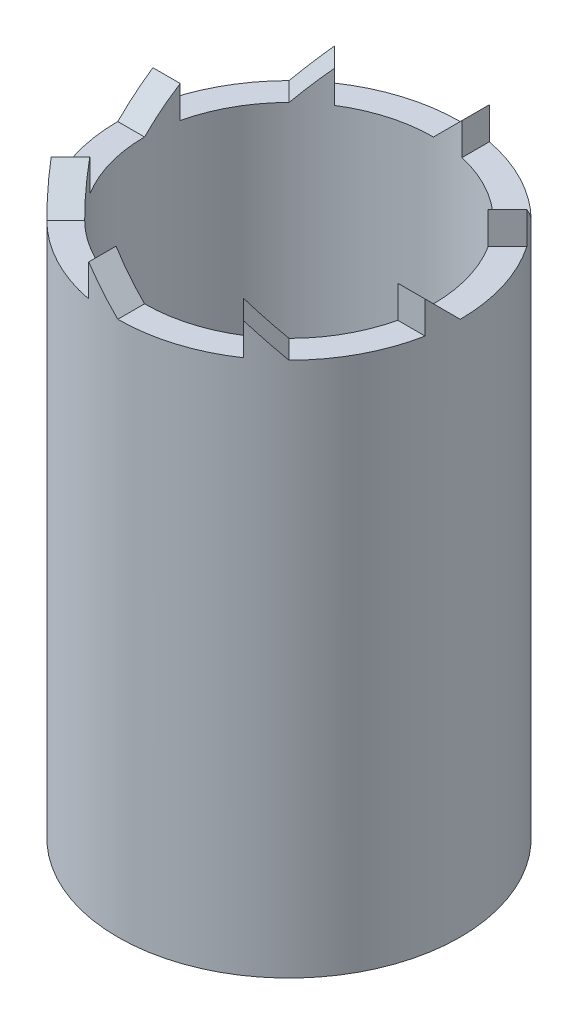
from build123d import *

# Parameters (mm, degrees)
SKETCH1_R           = 8.25
SKETCH1_R_2         = 6.75
BOSS_EXTRUDE1_DEPTH = 25
SKETCH2_W           = 1.5
SKETCH2_H           = 1.75
SKETCH2_W_2         = 1.75
SKETCH2_H_2         = 1.5
SKETCH2_H_3         = 1.499622071
BOSS_EXTRUDE2_DEPTH = 1.5
CUT_EXTRUDE1_DEPTH  = 2.5
CUT_EXTRUDE2_DEPTH  = 2.5
CUT_EXTRUDE3_DEPTH  = 2.5
CUT_EXTRUDE4_DEPTH  = 2.5
SKETCH9_R           = 6.625
CUT_EXTRUDE7_DEPTH  = 2.5
CUT_EXTRUDE10_DEPTH = 20.91726189
CUT_EXTRUDE11_DEPTH = 20.91726189
CUT_EXTRUDE12_DEPTH = 20.91726189
CUT_EXTRUDE13_DEPTH = 20.91726189
SKETCH15_R          = 10.332276799
SKETCH15_R_2        = 8
CUT_EXTRUDE14_DEPTH = 35
SKETCH16_R          = 6.75
CUT_EXTRUDE15_DEPTH = 40


with BuildPart() as part:
    # Sketch1 → Boss-Extrude1 (new body)
    with BuildSketch(Plane(origin=(0, 0, 0), x_dir=(1, 0, 0), z_dir=(0, 1, 0))):
        Circle(SKETCH1_R)
        Circle(SKETCH1_R_2, mode=Mode.SUBTRACT)
    extrude(amount=BOSS_EXTRUDE1_DEPTH)

    # Sketch2 → Boss-Extrude2 (add)
    with BuildSketch(Plane(origin=(0, 25, 0), x_dir=(1, 0, 0), z_dir=(0, 1, 0))):
        with Locations((0.75, 7.375)):
            Rectangle(SKETCH2_W, SKETCH2_H)
        with Locations((7.375, -0.75)):
            Rectangle(SKETCH2_W_2, SKETCH2_H_2)
        with Locations((-0.75, -7.375)):
            Rectangle(SKETCH2_W, SKETCH2_H)
        with Locations((-7.375, 0.749811036)):
            Rectangle(SKETCH2_W_2, SKETCH2_H_3)
        Polygon((-5.833630945, 5.833630945), (-4.772970773, 6.894291117), (-3.535533906, 5.656854249), (-4.596194078, 4.596194078), align=None)
        Polygon((5.833630945, 5.833630945), (6.894291117, 4.772970773), (5.656854249, 3.535533906), (4.596194078, 4.596194078), align=None)
        Polygon((5.833630945, -5.833630945), (4.772970773, -6.894291117), (3.535533906, -5.656854249), (4.596194078, -4.596194078), align=None)
        Polygon((-5.833630945, -5.833630945), (-6.894291117, -4.772970773), (-5.656854249, -3.535533906), (-4.596194078, -4.596194078), align=None)
    extrude(amount=BOSS_EXTRUDE2_DEPTH)

    # Sketch5 → Cut-Extrude1 (cut)
    with BuildSketch(Plane.XY.offset(8.25)):
        Polygon((-1.5, 26.5), (0, 25), (0, 26.5), align=None)
    extrude(amount=-CUT_EXTRUDE1_DEPTH, mode=Mode.SUBTRACT)

    # Sketch6 → Cut-Extrude2 (cut)
    with BuildSketch(Plane.ZY.offset(8.25)):
        Polygon((0, 26.5), (-1.499622071, 26.5), (0, 25), align=None)
    extrude(amount=-CUT_EXTRUDE2_DEPTH, mode=Mode.SUBTRACT)

    # Sketch7 → Cut-Extrude3 (cut)
    with BuildSketch(Plane(origin=(0, 0, -8.25), x_dir=(-1, 0, 0), z_dir=(0, 0, -1))):
        Polygon((-1.5, 26.5), (0, 26.5), (0, 25), align=None)
    extrude(amount=-CUT_EXTRUDE3_DEPTH, mode=Mode.SUBTRACT)

    # Sketch8 → Cut-Extrude4 (cut)
    with BuildSketch(Plane(origin=(8.25, 0, 0), x_dir=(0, 0, -1), z_dir=(1, 0, 0))):
        Polygon((0, 26.5), (-1.5, 26.5), (0, 25), align=None)
    extrude(amount=-CUT_EXTRUDE4_DEPTH, mode=Mode.SUBTRACT)

    # Sketch9 → Cut-Extrude7 (cut)
    with BuildSketch(Plane(origin=(0, 25, 0), x_dir=(1, 0, 0), z_dir=(0, 1, 0))):
        Circle(SKETCH9_R)
    extrude(amount=CUT_EXTRUDE7_DEPTH, mode=Mode.SUBTRACT)

    # Sketch11 → Cut-Extrude10 (cut, through all)
    with BuildSketch(Plane(origin=(-5.833630945, 0, 5.833630945), x_dir=(0.707106781, 0, 0.707106781), z_dir=(-0.707106781, 0, 0.707106781))):
        Polygon((0, 25), (-1.5, 26.5), (0, 26.5), align=None)
    extrude(amount=-CUT_EXTRUDE10_DEPTH, mode=Mode.SUBTRACT)

    # Sketch12 → Cut-Extrude11 (cut, through all)
    with BuildSketch(Plane(origin=(-5.833630945, 0, -5.833630945), x_dir=(-0.707106781, 0, 0.707106781), z_dir=(-0.707106781, 0, -0.707106781))):
        Polygon((0, 25), (-1.5, 26.5), (0, 26.5), align=None)
    extrude(amount=-CUT_EXTRUDE11_DEPTH, mode=Mode.SUBTRACT)

    # Sketch13 → Cut-Extrude12 (cut, through all)
    with BuildSketch(Plane(origin=(5.833630945, 0, -5.833630945), x_dir=(-0.707106781, 0, -0.707106781), z_dir=(0.707106781, 0, -0.707106781))):
        Polygon((0, 25), (-1.5, 26.5), (0, 26.5), align=None)
    extrude(amount=-CUT_EXTRUDE12_DEPTH, mode=Mode.SUBTRACT)

    # Sketch14 → Cut-Extrude13 (cut, through all)
    with BuildSketch(Plane(origin=(5.833630945, 0, 5.833630945), x_dir=(0.707106781, 0, -0.707106781), z_dir=(0.707106781, 0, 0.707106781))):
        Polygon((0, 25), (-1.5, 26.5), (0, 26.5), align=None)
    extrude(amount=-CUT_EXTRUDE13_DEPTH, mode=Mode.SUBTRACT)

    # Sketch15 → Cut-Extrude14 (cut)
    with BuildSketch(Plane.XZ):
        Circle(SKETCH15_R)
        Circle(SKETCH15_R_2, mode=Mode.SUBTRACT)
    extrude(amount=-CUT_EXTRUDE14_DEPTH, mode=Mode.SUBTRACT)

    # Sketch16 → Cut-Extrude15 (cut)
    with BuildSketch(Plane(origin=(0, 0, 0), x_dir=(1, 0, 0), z_dir=(0, 1, 0))):
        Circle(SKETCH16_R)
    extrude(amount=CUT_EXTRUDE15_DEPTH, mode=Mode.SUBTRACT)


solid = part.part
